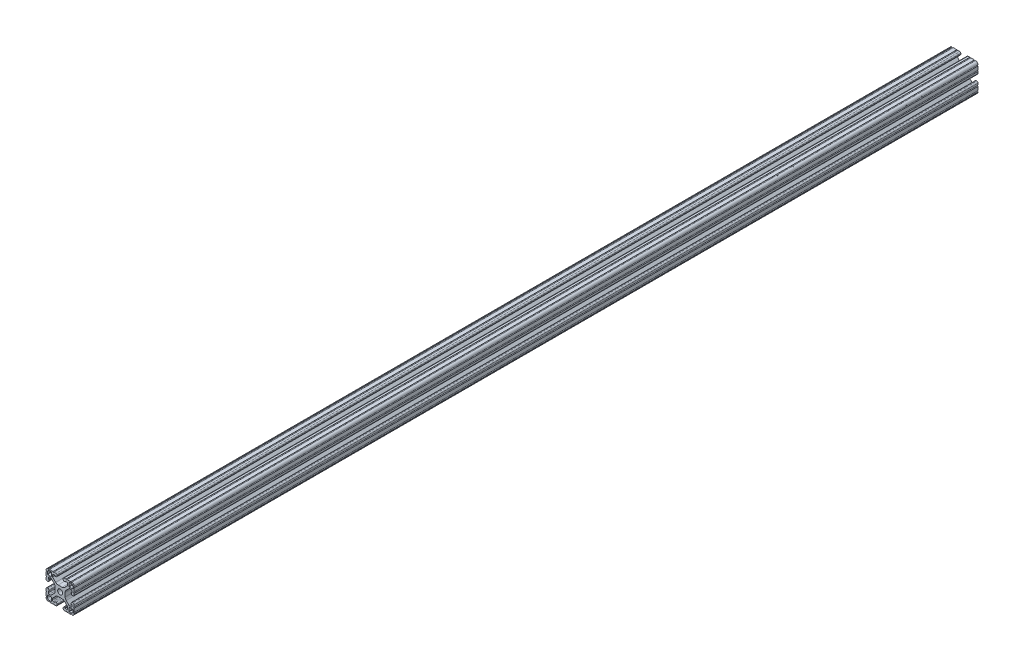
from build123d import *

# Parameters (mm, degrees)
SKETCH1_R      = 3.3274
EXTRUDE1_DEPTH = 1219.2


with BuildPart() as part:
    # Sketch1 → Extrude1 (new body)
    with BuildSketch(Plane.XY):
        with BuildLine():
            Line((10.02670034, -12.151875049), (6.021451835, -8.147301292))
            ThreePointArc((6.021451835, -8.147301292), (4.48060392, -7.11788044), (2.663118988, -6.7564))
            Line((2.663118988, -6.7564), (-2.663118988, -6.7564))
            ThreePointArc((-2.663118988, -6.7564), (-4.48060392, -7.11788044), (-6.021451835, -8.147301292))
            Line((-6.021451835, -8.147301292), (-10.02670034, -12.151875049))
            ThreePointArc((-10.02670034, -12.151875049), (-10.219349756, -12.440155844), (-10.287, -12.78021916))
            Line((-10.287, -12.78021916), (-10.287, -14.55471092))
            ThreePointArc((-10.287, -14.55471092), (-9.915025612, -15.452736532), (-9.017, -15.82471092))
            Line((-9.017, -15.82471092), (-6.814144259, -15.82471092))
            Line((-6.814144259, -15.82471092), (-6.814144259, -14.986))
            Line((-6.814144259, -14.986), (-5.6388, -14.986))
            ThreePointArc((-5.6388, -14.986), (-4.525248241, -15.447248241), (-4.064, -16.5608))
            Line((-4.064, -16.5608), (-4.064, -17.4752))
            ThreePointArc((-4.064, -17.4752), (-4.525248241, -18.588751759), (-5.6388, -19.05))
            Line((-5.6388, -19.05), (-7.9756, -19.05))
            ThreePointArc((-7.9756, -19.05), (-8.7376, -18.288), (-9.4996, -19.05))
            Line((-9.4996, -19.05), (-14.3256, -19.05))
            ThreePointArc((-14.3256, -19.05), (-15.0876, -18.288), (-15.8496, -19.05))
            Line((-15.8496, -19.05), (-15.875, -19.05))
            ThreePointArc((-15.875, -19.05), (-18.12006403, -18.12006403), (-19.05, -15.875))
            Line((-19.05, -15.875), (-19.05, -15.8496))
            ThreePointArc((-19.05, -15.8496), (-18.288, -15.0876), (-19.05, -14.3256))
            Line((-19.05, -14.3256), (-19.05, -9.4996))
            ThreePointArc((-19.05, -9.4996), (-18.288, -8.7376), (-19.05, -7.9756))
            Line((-19.05, -7.9756), (-19.05, -5.6388))
            ThreePointArc((-19.05, -5.6388), (-18.588751759, -4.525248241), (-17.4752, -4.064))
            Line((-17.4752, -4.064), (-16.5608, -4.064))
            ThreePointArc((-16.5608, -4.064), (-15.447248241, -4.525248241), (-14.986, -5.6388))
            Line((-14.986, -5.6388), (-14.986, -6.750644259))
            Line((-14.986, -6.750644259), (-15.879033733, -6.750644259))
            Line((-15.879033733, -6.750644259), (-15.879033733, -8.919211783))
            ThreePointArc((-15.879033733, -8.919211783), (-15.507059345, -9.817237395), (-14.609033733, -10.189211783))
            Line((-14.609033733, -10.189211783), (-12.742784468, -10.189211783))
            ThreePointArc((-12.742784468, -10.189211783), (-12.402613491, -10.121555016), (-12.114219497, -9.928882664))
            Line((-12.114219497, -9.928882664), (-8.147867153, -5.963198517))
            ThreePointArc((-8.147867153, -5.963198517), (-7.118033561, -4.422154408), (-6.7564, -2.604299809))
            Line((-6.7564, -2.604299809), (-6.7564, 2.604299809))
            ThreePointArc((-6.7564, 2.604299809), (-7.118033561, 4.422154408), (-8.147867153, 5.963198517))
            Line((-8.147867153, 5.963198517), (-12.114219497, 9.928882664))
            ThreePointArc((-12.114219497, 9.928882664), (-12.402613491, 10.121555016), (-12.742784468, 10.189211783))
            Line((-12.742784468, 10.189211783), (-14.609033733, 10.189211783))
            ThreePointArc((-14.609033733, 10.189211783), (-15.507059345, 9.817237395), (-15.879033733, 8.919211783))
            Line((-15.879033733, 8.919211783), (-15.879033733, 6.750644259))
            Line((-15.879033733, 6.750644259), (-14.986, 6.750644259))
            Line((-14.986, 6.750644259), (-14.986, 5.6388))
            ThreePointArc((-14.986, 5.6388), (-15.447248241, 4.525248241), (-16.5608, 4.064))
            Line((-16.5608, 4.064), (-17.4752, 4.064))
            ThreePointArc((-17.4752, 4.064), (-18.588751759, 4.525248241), (-19.05, 5.6388))
            Line((-19.05, 5.6388), (-19.05, 7.9756))
            ThreePointArc((-19.05, 7.9756), (-18.288, 8.7376), (-19.05, 9.4996))
            Line((-19.05, 9.4996), (-19.05, 14.3256))
            ThreePointArc((-19.05, 14.3256), (-18.288, 15.0876), (-19.05, 15.8496))
            Line((-19.05, 15.8496), (-19.05, 15.875))
            ThreePointArc((-19.05, 15.875), (-18.12006403, 18.12006403), (-15.875, 19.05))
            Line((-15.875, 19.05), (-15.8496, 19.05))
            ThreePointArc((-15.8496, 19.05), (-15.0876, 18.288), (-14.3256, 19.05))
            Line((-14.3256, 19.05), (-9.4996, 19.05))
            ThreePointArc((-9.4996, 19.05), (-8.7376, 18.288), (-7.9756, 19.05))
            Line((-7.9756, 19.05), (-5.6388, 19.05))
            ThreePointArc((-5.6388, 19.05), (-4.525248241, 18.588751759), (-4.064, 17.4752))
            Line((-4.064, 17.4752), (-4.064, 16.5608))
            ThreePointArc((-4.064, 16.5608), (-4.525248241, 15.447248241), (-5.6388, 14.986))
            Line((-5.6388, 14.986), (-6.814144259, 14.986))
            Line((-6.814144259, 14.986), (-6.814144259, 15.82471092))
            Line((-6.814144259, 15.82471092), (-9.017, 15.82471092))
            ThreePointArc((-9.017, 15.82471092), (-9.915025612, 15.452736532), (-10.287, 14.55471092))
            Line((-10.287, 14.55471092), (-10.287, 12.78021916))
            ThreePointArc((-10.287, 12.78021916), (-10.219349756, 12.440155844), (-10.02670034, 12.151875049))
            Line((-10.02670034, 12.151875049), (-6.021451835, 8.147301292))
            ThreePointArc((-6.021451835, 8.147301292), (-4.48060392, 7.11788044), (-2.663118988, 6.7564))
            Line((-2.663118988, 6.7564), (2.663118988, 6.7564))
            ThreePointArc((2.663118988, 6.7564), (4.48060392, 7.11788044), (6.021451835, 8.147301292))
            Line((6.021451835, 8.147301292), (10.02670034, 12.151875049))
            ThreePointArc((10.02670034, 12.151875049), (10.219349756, 12.440155844), (10.287, 12.78021916))
            Line((10.287, 12.78021916), (10.287, 14.55471092))
            ThreePointArc((10.287, 14.55471092), (9.915025612, 15.452736532), (9.017, 15.82471092))
            Line((9.017, 15.82471092), (6.814144259, 15.82471092))
            Line((6.814144259, 15.82471092), (6.814144259, 14.986))
            Line((6.814144259, 14.986), (5.6388, 14.986))
            ThreePointArc((5.6388, 14.986), (4.525248241, 15.447248241), (4.064, 16.5608))
            Line((4.064, 16.5608), (4.064, 17.4752))
            ThreePointArc((4.064, 17.4752), (4.525248241, 18.588751759), (5.6388, 19.05))
            Line((5.6388, 19.05), (7.9756, 19.05))
            ThreePointArc((7.9756, 19.05), (8.7376, 18.288), (9.4996, 19.05))
            Line((9.4996, 19.05), (14.3256, 19.05))
            ThreePointArc((14.3256, 19.05), (15.0876, 18.288), (15.8496, 19.05))
            Line((15.8496, 19.05), (15.875, 19.05))
            ThreePointArc((15.875, 19.05), (18.12006403, 18.12006403), (19.05, 15.875))
            Line((19.05, 15.875), (19.05, 15.8496))
            ThreePointArc((19.05, 15.8496), (18.288, 15.0876), (19.05, 14.3256))
            Line((19.05, 14.3256), (19.05, 9.4996))
            ThreePointArc((19.05, 9.4996), (18.288, 8.7376), (19.05, 7.9756))
            Line((19.05, 7.9756), (19.05, 5.6388))
            ThreePointArc((19.05, 5.6388), (18.588751759, 4.525248241), (17.4752, 4.064))
            Line((17.4752, 4.064), (16.5608, 4.064))
            ThreePointArc((16.5608, 4.064), (15.447248241, 4.525248241), (14.986, 5.6388))
            Line((14.986, 5.6388), (14.986, 6.750644259))
            Line((14.986, 6.750644259), (15.879033733, 6.750644259))
            Line((15.879033733, 6.750644259), (15.879033733, 8.919211783))
            ThreePointArc((15.879033733, 8.919211783), (15.507059345, 9.817237395), (14.609033733, 10.189211783))
            Line((14.609033733, 10.189211783), (12.742784468, 10.189211783))
            ThreePointArc((12.742784468, 10.189211783), (12.402613491, 10.121555016), (12.114219497, 9.928882664))
            Line((12.114219497, 9.928882664), (8.147867153, 5.963198517))
            ThreePointArc((8.147867153, 5.963198517), (7.118033561, 4.422154408), (6.7564, 2.604299809))
            Line((6.7564, 2.604299809), (6.7564, -2.604299809))
            ThreePointArc((6.7564, -2.604299809), (7.118033561, -4.422154408), (8.147867153, -5.963198517))
            Line((8.147867153, -5.963198517), (12.114219497, -9.928882664))
            ThreePointArc((12.114219497, -9.928882664), (12.402613491, -10.121555016), (12.742784468, -10.189211783))
            Line((12.742784468, -10.189211783), (14.609033733, -10.189211783))
            ThreePointArc((14.609033733, -10.189211783), (15.507059345, -9.817237395), (15.879033733, -8.919211783))
            Line((15.879033733, -8.919211783), (15.879033733, -6.750644259))
            Line((15.879033733, -6.750644259), (14.986, -6.750644259))
            Line((14.986, -6.750644259), (14.986, -5.6388))
            ThreePointArc((14.986, -5.6388), (15.447248241, -4.525248241), (16.5608, -4.064))
            Line((16.5608, -4.064), (17.4752, -4.064))
            ThreePointArc((17.4752, -4.064), (18.588751759, -4.525248241), (19.05, -5.6388))
            Line((19.05, -5.6388), (19.05, -7.9756))
            ThreePointArc((19.05, -7.9756), (18.288, -8.7376), (19.05, -9.4996))
            Line((19.05, -9.4996), (19.05, -14.3256))
            ThreePointArc((19.05, -14.3256), (18.288, -15.0876), (19.05, -15.8496))
            Line((19.05, -15.8496), (19.05, -15.875))
            ThreePointArc((19.05, -15.875), (18.12006403, -18.12006403), (15.875, -19.05))
            Line((15.875, -19.05), (15.8496, -19.05))
            ThreePointArc((15.8496, -19.05), (15.0876, -18.288), (14.3256, -19.05))
            Line((14.3256, -19.05), (9.4996, -19.05))
            ThreePointArc((9.4996, -19.05), (8.7376, -18.288), (7.9756, -19.05))
            Line((7.9756, -19.05), (5.6388, -19.05))
            ThreePointArc((5.6388, -19.05), (4.525248241, -18.588751759), (4.064, -17.4752))
            Line((4.064, -17.4752), (4.064, -16.5608))
            ThreePointArc((4.064, -16.5608), (4.525248241, -15.447248241), (5.6388, -14.986))
            Line((5.6388, -14.986), (6.814144259, -14.986))
            Line((6.814144259, -14.986), (6.814144259, -15.82471092))
            Line((6.814144259, -15.82471092), (9.017, -15.82471092))
            ThreePointArc((9.017, -15.82471092), (9.915025612, -15.452736532), (10.287, -14.55471092))
            Line((10.287, -14.55471092), (10.287, -12.78021916))
            ThreePointArc((10.287, -12.78021916), (10.219349756, -12.440155844), (10.02670034, -12.151875049))
        make_face()
        Circle(SKETCH1_R, mode=Mode.SUBTRACT)
        with BuildLine():
            Line((16.891, -11.8618), (12.2428, -11.8618))
            ThreePointArc((12.2428, -11.8618), (11.973392316, -11.973392316), (11.8618, -12.2428))
            Line((11.8618, -12.2428), (11.8618, -16.891))
            ThreePointArc((11.8618, -16.891), (11.973392316, -17.160407684), (12.2428, -17.272))
            Line((12.2428, -17.272), (14.478, -17.272))
            ThreePointArc((14.478, -17.272), (16.453656347, -16.453656347), (17.272, -14.478))
            Line((17.272, -14.478), (17.272, -12.2428))
            ThreePointArc((17.272, -12.2428), (17.160407684, -11.973392316), (16.891, -11.8618))
        make_face(mode=Mode.SUBTRACT)
        with BuildLine():
            Line((17.272, 14.478), (17.272, 12.2428))
            ThreePointArc((17.272, 12.2428), (17.160407684, 11.973392316), (16.891, 11.8618))
            Line((16.891, 11.8618), (12.2428, 11.8618))
            ThreePointArc((12.2428, 11.8618), (11.973392316, 11.973392316), (11.8618, 12.2428))
            Line((11.8618, 12.2428), (11.8618, 16.891))
            ThreePointArc((11.8618, 16.891), (11.973392316, 17.160407684), (12.2428, 17.272))
            Line((12.2428, 17.272), (14.478, 17.272))
            ThreePointArc((14.478, 17.272), (16.453656347, 16.453656347), (17.272, 14.478))
        make_face(mode=Mode.SUBTRACT)
        with BuildLine():
            Line((-17.272, -14.478), (-17.272, -12.2428))
            ThreePointArc((-17.272, -12.2428), (-17.160407684, -11.973392316), (-16.891, -11.8618))
            Line((-16.891, -11.8618), (-12.2428, -11.8618))
            ThreePointArc((-12.2428, -11.8618), (-11.973392316, -11.973392316), (-11.8618, -12.2428))
            Line((-11.8618, -12.2428), (-11.8618, -16.891))
            ThreePointArc((-11.8618, -16.891), (-11.973392316, -17.160407684), (-12.2428, -17.272))
            Line((-12.2428, -17.272), (-14.478, -17.272))
            ThreePointArc((-14.478, -17.272), (-16.453656347, -16.453656347), (-17.272, -14.478))
        make_face(mode=Mode.SUBTRACT)
        with BuildLine():
            Line((-16.891, 11.8618), (-12.2428, 11.8618))
            ThreePointArc((-12.2428, 11.8618), (-11.973392316, 11.973392316), (-11.8618, 12.2428))
            Line((-11.8618, 12.2428), (-11.8618, 16.891))
            ThreePointArc((-11.8618, 16.891), (-11.973392316, 17.160407684), (-12.2428, 17.272))
            Line((-12.2428, 17.272), (-14.478, 17.272))
            ThreePointArc((-14.478, 17.272), (-16.453656347, 16.453656347), (-17.272, 14.478))
            Line((-17.272, 14.478), (-17.272, 12.2428))
            ThreePointArc((-17.272, 12.2428), (-17.160407684, 11.973392316), (-16.891, 11.8618))
        make_face(mode=Mode.SUBTRACT)
    extrude(amount=-EXTRUDE1_DEPTH)


solid = part.part
